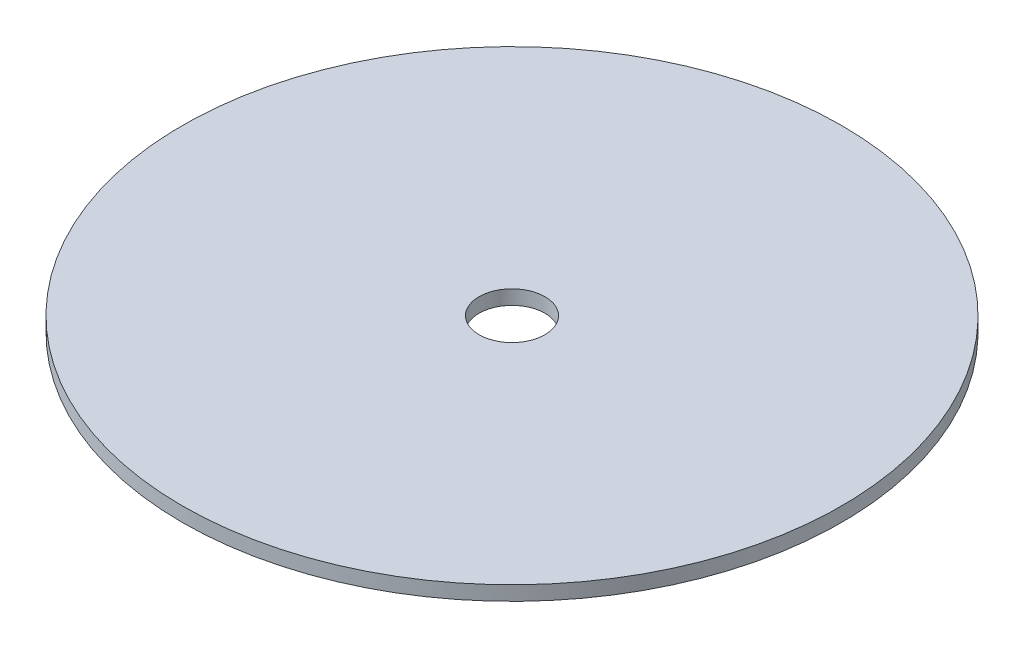
from build123d import *

# Parameters (mm, degrees)
SKETCH1_R           = 114.3
SKETCH1_R_2         = 9.525
BOSS_EXTRUDE1_DEPTH = 4.16
SKETCH2_R           = 131.950649673
SKETCH2_R_2         = 95.25
CUT_EXTRUDE1_DEPTH  = 5.16


with BuildPart() as part:
    # Sketch1 → Boss-Extrude1 (new body)
    with BuildSketch(Plane(origin=(0, 0, 0), x_dir=(1, 0, 0), z_dir=(0, 1, 0))):
        Circle(SKETCH1_R)
        Circle(SKETCH1_R_2, mode=Mode.SUBTRACT)
    extrude(amount=BOSS_EXTRUDE1_DEPTH)

    # Sketch2 → Cut-Extrude1 (cut, through all)
    with BuildSketch(Plane(origin=(0, 4.16, 0), x_dir=(1, 0, 0), z_dir=(0, 1, 0))):
        Circle(SKETCH2_R)
        Circle(SKETCH2_R_2, mode=Mode.SUBTRACT)
    extrude(amount=-CUT_EXTRUDE1_DEPTH, mode=Mode.SUBTRACT)


solid = part.part
